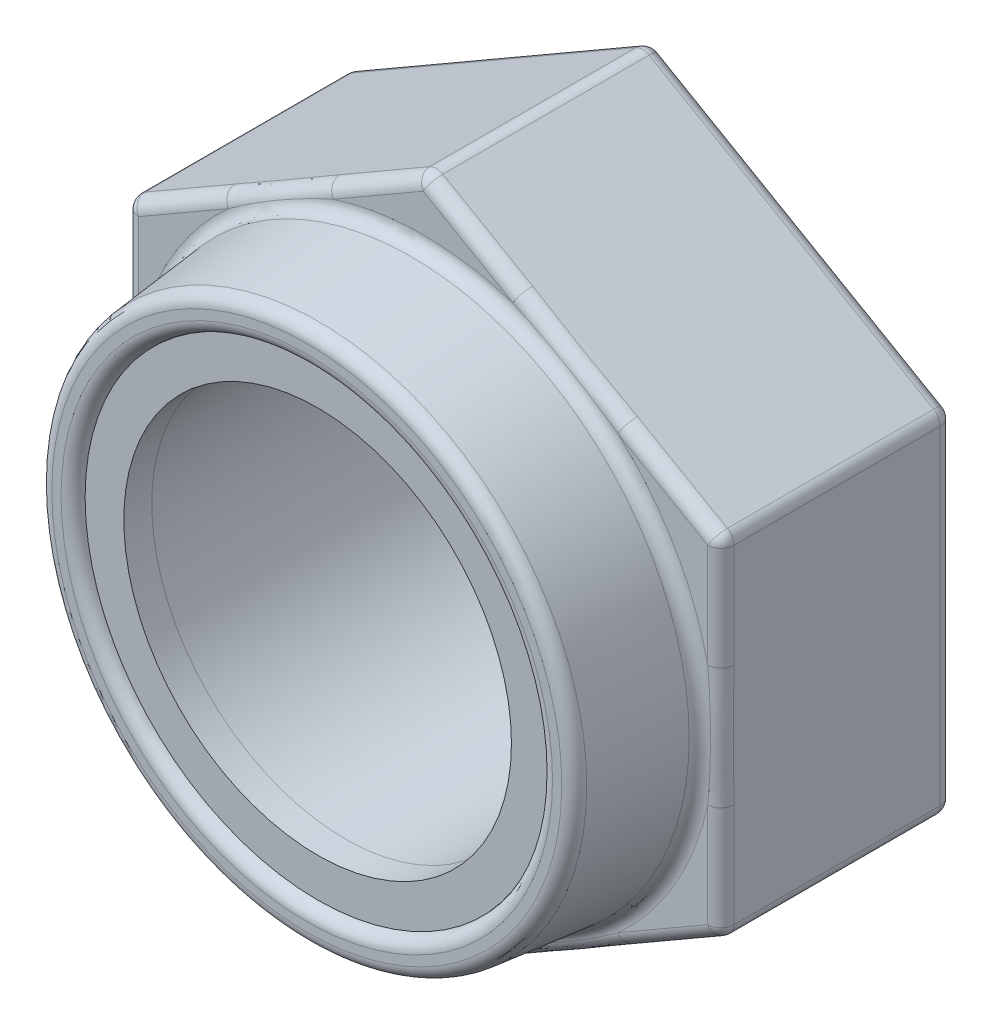
from build123d import *

# Parameters (mm, degrees)
BOSS_EXTRUDE1_DEPTH = 3
SKETCH2_R           = 3.6
BOSS_EXTRUDE2_DEPTH = 1.5
BOSS_EXTRUDE2_TAPER = 6
SKETCH3_R           = 2.5
CUT_EXTRUDE1_DEPTH  = 5.5
SKETCH4_R           = 3
CUT_EXTRUDE2_DEPTH  = 0.5
FILLET2_R           = 0.17
FILLET3_R           = 0.17
SKETCH5_R           = 3
BOSS_EXTRUDE4_DEPTH = 0.36
SKETCH8_R           = 2.5
CUT_EXTRUDE3_DEPTH  = 0.36
FILLET4_R           = 0.17
FILLET5_R           = 0.17


with BuildPart() as part:
    # Sketch1 → Boss-Extrude1 (new body)
    with BuildSketch(Plane.XY):
        Polygon((3.840822666, -2.2175), (3.840822666, 2.2175), (0, 4.435), (-3.840822666, 2.2175), (-3.840822666, -2.2175), (0, -4.435), align=None)
    extrude(amount=BOSS_EXTRUDE1_DEPTH)

    # Sketch2 → Boss-Extrude2 (add)
    with BuildSketch(Plane.XY.offset(3)):
        Circle(SKETCH2_R)
    extrude(amount=BOSS_EXTRUDE2_DEPTH, taper=BOSS_EXTRUDE2_TAPER)

    # Sketch3 → Cut-Extrude1 (cut, through all)
    with BuildSketch(Plane.XY.offset(4.5)):
        Circle(SKETCH3_R)
    extrude(amount=-CUT_EXTRUDE1_DEPTH, mode=Mode.SUBTRACT)

    # Sketch4 → Cut-Extrude2 (cut)
    with BuildSketch(Plane.XY.offset(4.5)):
        Circle(SKETCH4_R)
    extrude(amount=-CUT_EXTRUDE2_DEPTH, mode=Mode.SUBTRACT)

    # Fillet2
    fillet2_edges = [part.edges().sort_by_distance(p)[0] for p in [
        (-3.442343647, 0, 4.5),
    ]]
    fillet(fillet2_edges, radius=FILLET2_R)

    # Fillet3
    fillet3_edges = [part.edges().sort_by_distance(p)[0] for p in [
        (-3, 0, 4.5),
    ]]
    fillet(fillet3_edges, radius=FILLET3_R)

    # Fillet4
    fillet4_edges = [part.edges().sort_by_distance(p)[0] for p in [
        (-3.6, 0, 3),
    ]]
    fillet(fillet4_edges, radius=FILLET4_R)

    # Fillet5
    fillet5_edges = [part.edges().sort_by_distance(p)[0] for p in [
        (1.920411333, 3.32625, 3),
        (0, -4.435, 1.5),
        (-3.840822666, -2.2175, 1.5),
        (-3.840822666, 2.2175, 1.5),
        (0, 4.435, 1.5),
        (3.840822666, 2.2175, 1.5),
        (3.840822666, -2.2175, 1.5),
        (-1.920411333, 3.32625, 3),
        (-3.840822666, 0, 3),
        (-1.920411333, -3.32625, 3),
        (1.920411333, -3.32625, 3),
        (-1.920411333, -3.32625, 0),
        (-3.840822666, 0, 0),
        (-1.920411333, 3.32625, 0),
        (3.840822666, 0, 3),
        (1.920411333, 3.32625, 0),
        (3.840822666, 0, 0),
        (1.920411333, -3.32625, 0),
    ]]
    fillet(fillet5_edges, radius=FILLET5_R)


with BuildPart() as body_2:
    # Sketch5 → Boss-Extrude4 (new body)
    with BuildSketch(Plane.XY.offset(4)):
        Circle(SKETCH5_R)
    extrude(amount=BOSS_EXTRUDE4_DEPTH)

    # Sketch8 → Cut-Extrude3 (cut)
    with BuildSketch(Plane.XY.offset(4.36)):
        Circle(SKETCH8_R)
    extrude(amount=-CUT_EXTRUDE3_DEPTH, mode=Mode.SUBTRACT)


solid = Compound([part.part, body_2.part])
